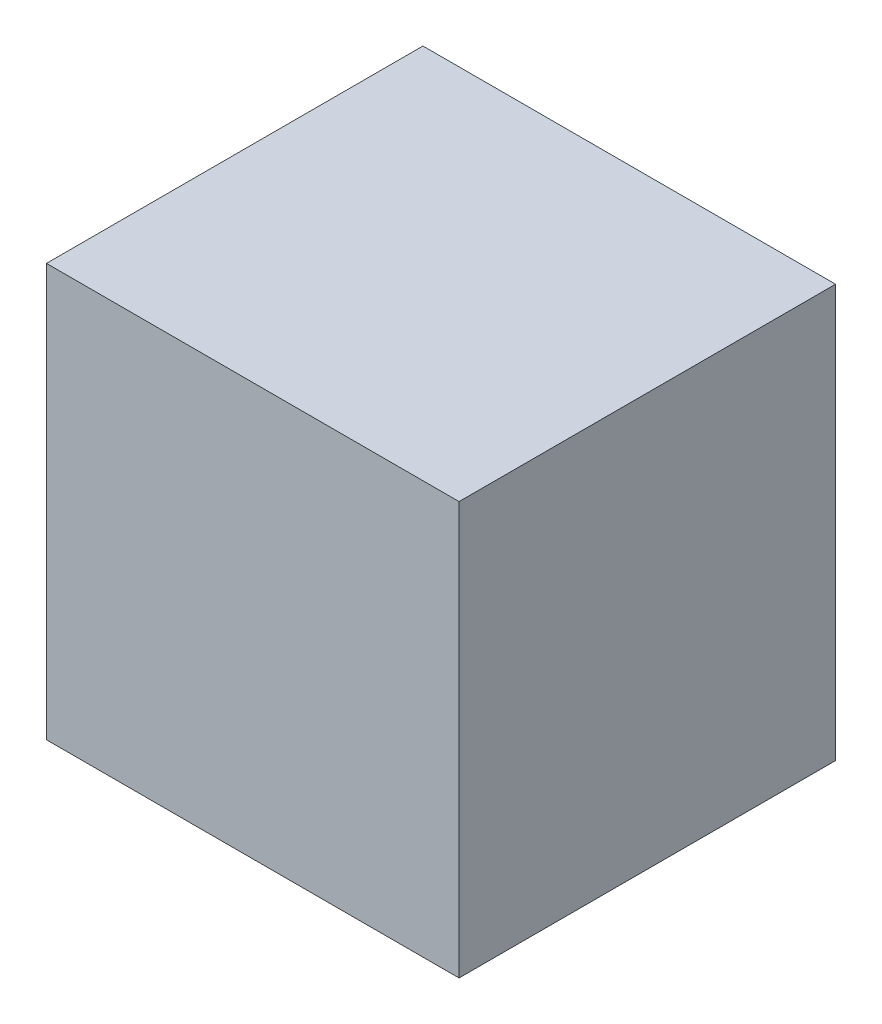
from build123d import *

# Parameters (mm, degrees)
SKETCH1_W           = 254
SKETCH1_H           = 231.775
BOSS_EXTRUDE1_DEPTH = 254


with BuildPart() as part:
    # Sketch1 → Boss-Extrude1 (new body)
    with BuildSketch(Plane(origin=(0, 0, 0), x_dir=(1, 0, 0), z_dir=(0, 1, 0))):
        with Locations((127, 115.8875)):
            Rectangle(SKETCH1_W, SKETCH1_H)
    extrude(amount=BOSS_EXTRUDE1_DEPTH)


solid = part.part
